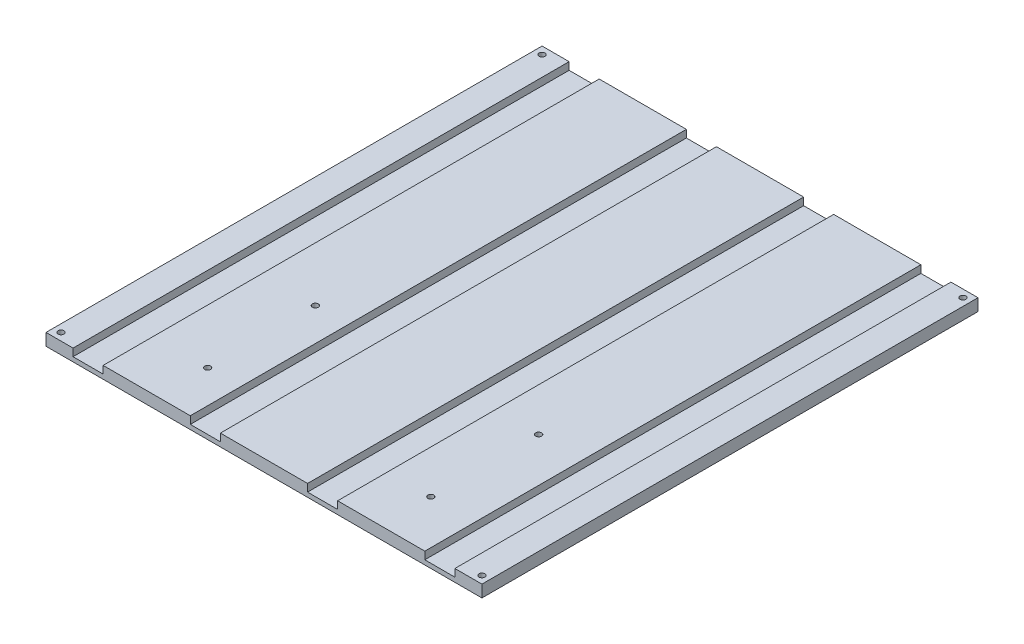
from build123d import *

# Parameters (mm, degrees)
SKETCH2_W           = 145
SKETCH2_H           = 165
BOSS_EXTRUDE1_DEPTH = 4
SKETCH2_3_W         = 10
SKETCH2_3_H         = 165
CUT_EXTRUDE1_DEPTH  = 2.5
SKETCH3_R           = 0.98
CUT_EXTRUDE3_DEPTH  = 5
SKETCH5_R           = 0.98
CUT_EXTRUDE4_DEPTH  = 4


with BuildPart() as part:
    # Sketch2 → Boss-Extrude1 (new body)
    with BuildSketch(Plane(origin=(0, 0, 0), x_dir=(1, 0, 0), z_dir=(0, 1, 0))):
        Rectangle(SKETCH2_W, SKETCH2_H)
    extrude(amount=-BOSS_EXTRUDE1_DEPTH)

    # Sketch2_3 → Cut-Extrude1 (cut)
    with BuildSketch(Plane(origin=(0, 0, 0), x_dir=(1, 0, 0), z_dir=(0, 1, 0))):
        with Locations((-19.5, 0)):
            Rectangle(SKETCH2_3_W, SKETCH2_3_H)
        with Locations((-58.5, 0)):
            Rectangle(SKETCH2_3_W, SKETCH2_3_H)
        with Locations((19.5, 0)):
            Rectangle(SKETCH2_3_W, SKETCH2_3_H)
        with Locations((58.5, 0)):
            Rectangle(SKETCH2_3_W, SKETCH2_3_H)
    extrude(amount=-CUT_EXTRUDE1_DEPTH, mode=Mode.SUBTRACT)

    # Sketch3 → Cut-Extrude3 (cut)
    with BuildSketch(Plane.XZ.offset(4)):
        with Locations((-70, 80)):
            Circle(SKETCH3_R)
        with Locations((70, 80)):
            Circle(SKETCH3_R)
        with Locations((70, -80)):
            Circle(SKETCH3_R)
        with Locations((-70, -80)):
            Circle(SKETCH3_R)
    extrude(amount=-CUT_EXTRUDE3_DEPTH, mode=Mode.SUBTRACT)

    # Sketch5 → Cut-Extrude4 (cut)
    with BuildSketch(Plane(origin=(0, -4, 0), x_dir=(1, 0, 0), z_dir=(0, 1, 0))):
        with Locations((-35.438735521, -29.971809351)):
            Circle(SKETCH5_R)
        with Locations((38.831264479, -29.971809351)):
            Circle(SKETCH5_R)
        with Locations((38.831264479, -65.811809351)):
            Circle(SKETCH5_R)
        with Locations((-35.438735521, -65.811809351)):
            Circle(SKETCH5_R)
    extrude(amount=CUT_EXTRUDE4_DEPTH, mode=Mode.SUBTRACT)


solid = part.part
